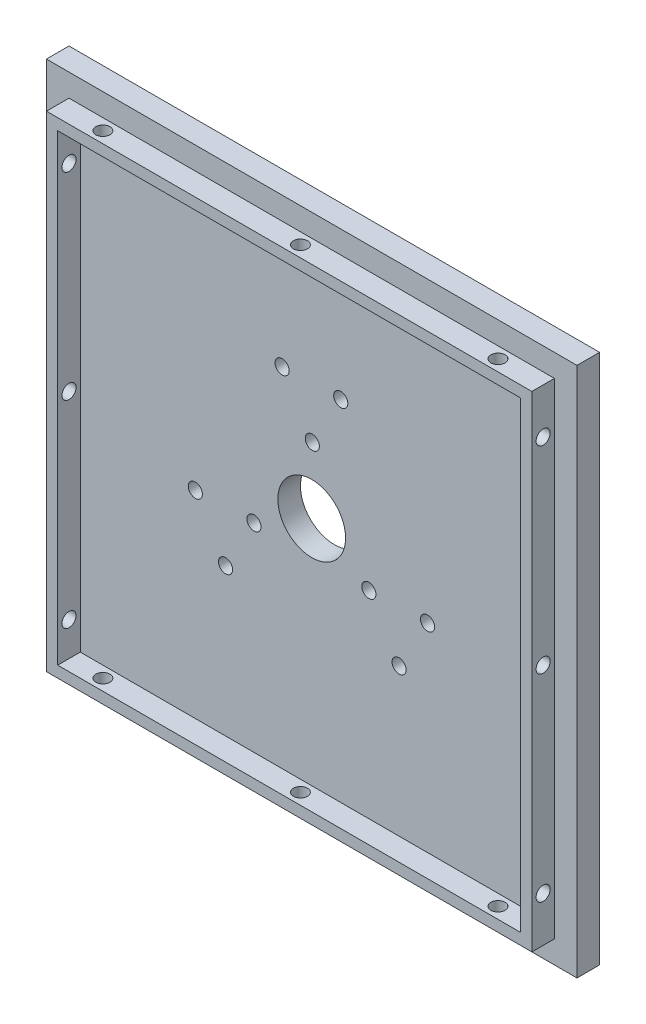
from build123d import *

# Parameters (mm, degrees)
SKETCH_1_R               = 1.25
SKETCH_1_R_2             = 6
EXTRUDE_1_DEPTH          = 4
SKETCH_3_W               = 2
SKETCH_3_H               = 4
EXTRUDE_2_DEPTH          = 43
SKETCH_4_W               = 4
SKETCH_4_H               = 2
EXTRUDE_3_DEPTH          = 43
SKETCH_5_R               = 1.25
CUT_EXTRUDE_1_DEPTH      = 2
PATTERN_CIRCULAR_1_COUNT = 4


with BuildPart() as part:
    # 草图1 → 凸台-拉伸1 (new body)
    with BuildSketch(Plane.XY):
        Polygon((47, 47), (0, 47), (-47, 47), (-47, 0), (-47, -47), (0, -47), (47, -47), (47, 0), align=None)
        with Locations((-15.266370453, -14.873586171)):
            Circle(SKETCH_1_R, mode=Mode.SUBTRACT)
        with Locations((-20.618803135, -5.965642279)):
            Circle(SKETCH_1_R, mode=Mode.SUBTRACT)
        with Locations((-10.228081088, -5.784271551)):
            Circle(SKETCH_1_R, mode=Mode.SUBTRACT)
        with Locations((15.47579933, -14.873586171)):
            Circle(SKETCH_1_R, mode=Mode.SUBTRACT)
        with Locations((10.123366649, -5.965642279)):
            Circle(SKETCH_1_R, mode=Mode.SUBTRACT)
        with Locations((20.514088696, -5.784271551)):
            Circle(SKETCH_1_R, mode=Mode.SUBTRACT)
        with Locations((-5.247718243, 20.657857721)):
            Circle(SKETCH_1_R, mode=Mode.SUBTRACT)
        Circle(SKETCH_1_R_2, mode=Mode.SUBTRACT)
        with Locations((0.104714439, 11.749913829)):
            Circle(SKETCH_1_R, mode=Mode.SUBTRACT)
        with Locations((5.143003804, 20.839228449)):
            Circle(SKETCH_1_R, mode=Mode.SUBTRACT)
    extrude(amount=EXTRUDE_1_DEPTH)

    # 草图3 → 凸台-拉伸2 (add, symmetric)
    with BuildSketch(Plane(origin=(0, 0, 0), x_dir=(1, 0, 0), z_dir=(0, 1, 0))):
        with Locations((-42, -6)):
            Rectangle(SKETCH_3_W, SKETCH_3_H)
        with Locations((42, -6)):
            Rectangle(SKETCH_3_W, SKETCH_3_H)
    extrude(amount=EXTRUDE_2_DEPTH, both=True)

    # 草图4 → 凸台-拉伸3 (add, symmetric)
    with BuildSketch(Plane(origin=(0, 0, 0), x_dir=(0, 0, -1), z_dir=(1, 0, 0))):
        with Locations((-6, -42)):
            Rectangle(SKETCH_4_W, SKETCH_4_H)
        with Locations((-6, 42)):
            Rectangle(SKETCH_4_W, SKETCH_4_H)
    extrude(amount=EXTRUDE_3_DEPTH, both=True)

    # 草图5 → 切除-拉伸1 (cut)
    with BuildSketch(Plane(origin=(0, 43, 0), x_dir=(1, 0, 0), z_dir=(0, 1, 0))):
        with Locations((0, -6)):
            Circle(SKETCH_5_R)
        with Locations((35, -6)):
            Circle(SKETCH_5_R)
        with Locations((-35, -6)):
            Circle(SKETCH_5_R)
    cut_extrude_1 = extrude(amount=-CUT_EXTRUDE_1_DEPTH, mode=Mode.SUBTRACT)

    # 阵列(圆周)1: 切除-拉伸1 ×4 about axis
    pattern_circular_1_axis = Axis((0, 0, 4), (0, 0, 1))
    for i in range(1, PATTERN_CIRCULAR_1_COUNT):
        add(cut_extrude_1.rotate(pattern_circular_1_axis, i * 360 / PATTERN_CIRCULAR_1_COUNT), mode=Mode.SUBTRACT)


solid = part.part
